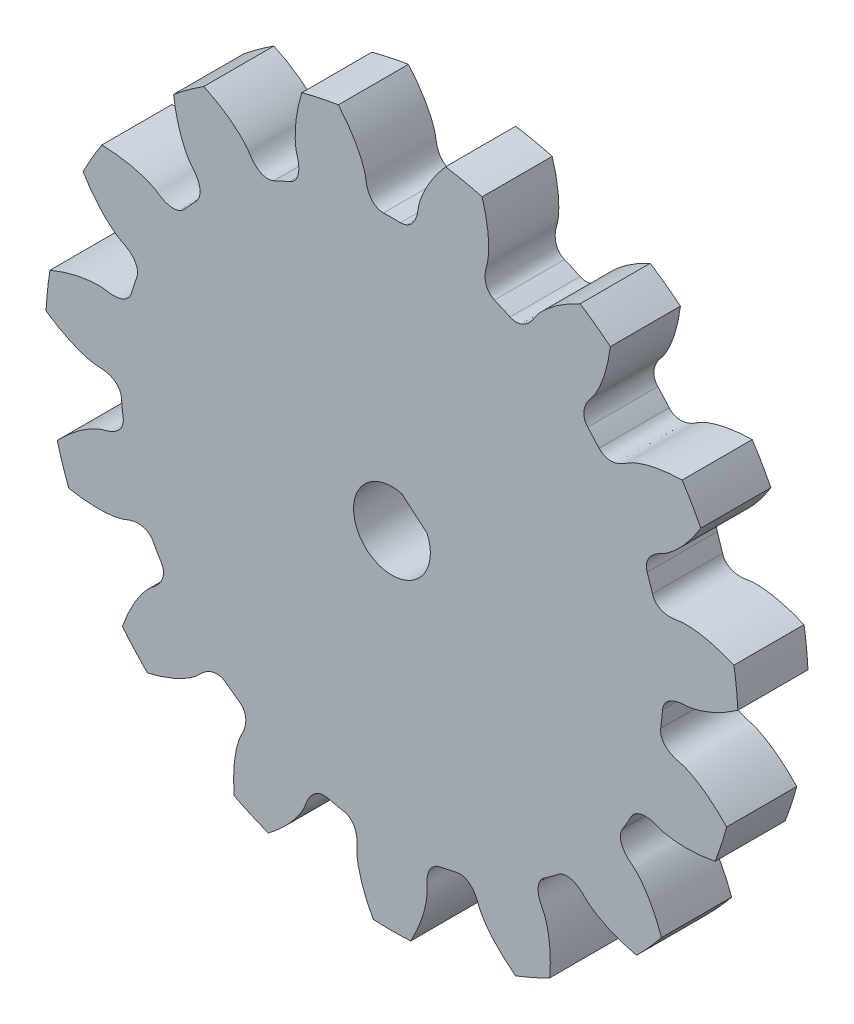
from build123d import *

# Parameters (mm, degrees)
GEAR_BASESKETCH_R                        = 26.3525
F_8_0_DIAMETRAL_PITCH_1_8750IN_P_D_DEPTH = 2.667
TOOTH_CUT_STUB_INVOLUTE_20_DEG_DEPTH     = 3.667
TOOTH_PATTERN_15_15_COUNT                = 15
CUT_EXTRUDE1_DEPTH                       = 6.3340001


with BuildPart() as part:
    # Gear-BaseSketch → 8.0 Diametral Pitch_ 1.8750in P.D (new body, symmetric)
    with BuildSketch(Plane.XY):
        Circle(GEAR_BASESKETCH_R)
    extrude(amount=F_8_0_DIAMETRAL_PITCH_1_8750IN_P_D_DEPTH, both=True)

    # Tooth-Sketch_ Backlash_ 0.0000in → Tooth-Cut_ Stub Involute 20 deg (cut, symmetric)
    with BuildSketch(Plane.XY):
        with BuildLine():
            ThreePointArc((-4.148755429, 26.115770886), (0, 26.443253593), (4.148755429, 26.115770886))
            add(Edge.make_bspline(
                [(4.148755429, 26.115770886), (4.024813143, 25.970952617), (3.785476315, 25.691303544), (3.461022479, 25.268989318), (3.176182838, 24.866589207), (2.930124101, 24.485519409), (2.720171422, 24.128531011), (2.543916186, 23.797861115), (2.398727533, 23.495662175), (2.281880986, 23.223892898), (2.190534345, 22.984337049), (2.121766139, 22.778589189), (2.072521828, 22.608060905), (2.039799567, 22.473948871), (2.02021996, 22.377300534), (2.009931021, 22.311775371), (1.999778624, 22.230615799), (1.985418832, 22.122649518), (1.960305598, 21.984230908), (1.920825254, 21.808633933), (1.858063949, 21.598977451), (1.756180953, 21.359548622), (1.619144668, 21.131271573), (1.428746587, 20.913809412), (1.159754501, 20.724076979), (0.879509261, 20.636270848), (0.700065738, 20.62945835), (0.645727637, 20.627395426)],
                knots=[0, 0, 0, 0, 0.084110659, 0.162420583, 0.234929773, 0.301638227, 0.362545948, 0.417652933, 0.466959184, 0.510464701, 0.548169484, 0.580073532, 0.606176847, 0.62647943, 0.640981281, 0.649682407, 0.655744169, 0.677077865, 0.697741103, 0.717804548, 0.756491825, 0.794148783, 0.832356747, 0.873539208, 0.920815846, 0.97602189, 1, 1, 1, 1], degree=3))
            ThreePointArc((0.645727637, 20.627395426), (0, 20.6375), (-0.645727637, 20.627395426))
            add(Edge.make_bspline(
                [(-4.148755429, 26.115770886), (-4.024813143, 25.970952617), (-3.785476315, 25.691303544), (-3.461022479, 25.268989318), (-3.176182838, 24.866589207), (-2.930124101, 24.485519409), (-2.720171422, 24.128531011), (-2.543916186, 23.797861115), (-2.398727533, 23.495662175), (-2.281880986, 23.223892898), (-2.190534345, 22.984337049), (-2.121766139, 22.778589189), (-2.072521828, 22.608060905), (-2.039799567, 22.473948871), (-2.02021996, 22.377300534), (-2.009931021, 22.311775371), (-1.999778624, 22.230615799), (-1.985418832, 22.122649518), (-1.960305598, 21.984230908), (-1.920825254, 21.808633933), (-1.858063949, 21.598977451), (-1.756180953, 21.359548622), (-1.619144668, 21.131271573), (-1.428746587, 20.913809412), (-1.159754501, 20.724076979), (-0.879509261, 20.636270848), (-0.700065738, 20.62945835), (-0.645727637, 20.627395426)],
                knots=[0, 0, 0, 0, 0.084110659, 0.162420583, 0.234929773, 0.301638227, 0.362545948, 0.417652933, 0.466959184, 0.510464701, 0.548169484, 0.580073532, 0.606176847, 0.62647943, 0.640981281, 0.649682407, 0.655744169, 0.677077865, 0.697741103, 0.717804548, 0.756491825, 0.794148783, 0.832356747, 0.873539208, 0.920815846, 0.97602189, 1, 1, 1, 1], degree=3))
        make_face()
    tooth_cut_stub_involute_20_deg = extrude(amount=TOOTH_CUT_STUB_INVOLUTE_20_DEG_DEPTH, both=True, mode=Mode.SUBTRACT)

    # Tooth Pattern_ 15 _ 15: Tooth-Cut_ Stub Involute 20 deg ×15 about axis
    tooth_pattern_15_15_axis = Axis((0, 0, -88.99), (0, 0, 1))
    for i in range(1, TOOTH_PATTERN_15_15_COUNT):
        add(tooth_cut_stub_involute_20_deg.rotate(tooth_pattern_15_15_axis, i * 360 / TOOTH_PATTERN_15_15_COUNT), mode=Mode.SUBTRACT)

    # Sketch4 → Cut-Extrude1 (cut, through all)
    with BuildSketch(Plane.XY.offset(2.667)):
        with BuildLine():
            Line((0.757484142, 2.821074046), (2.671347237, 1.181585772))
            ThreePointArc((2.671347237, 1.181585772), (-1.900316186, -2.218341586), (0.757484142, 2.821074046))
        make_face()
    extrude(amount=-CUT_EXTRUDE1_DEPTH, mode=Mode.SUBTRACT)


solid = part.part
